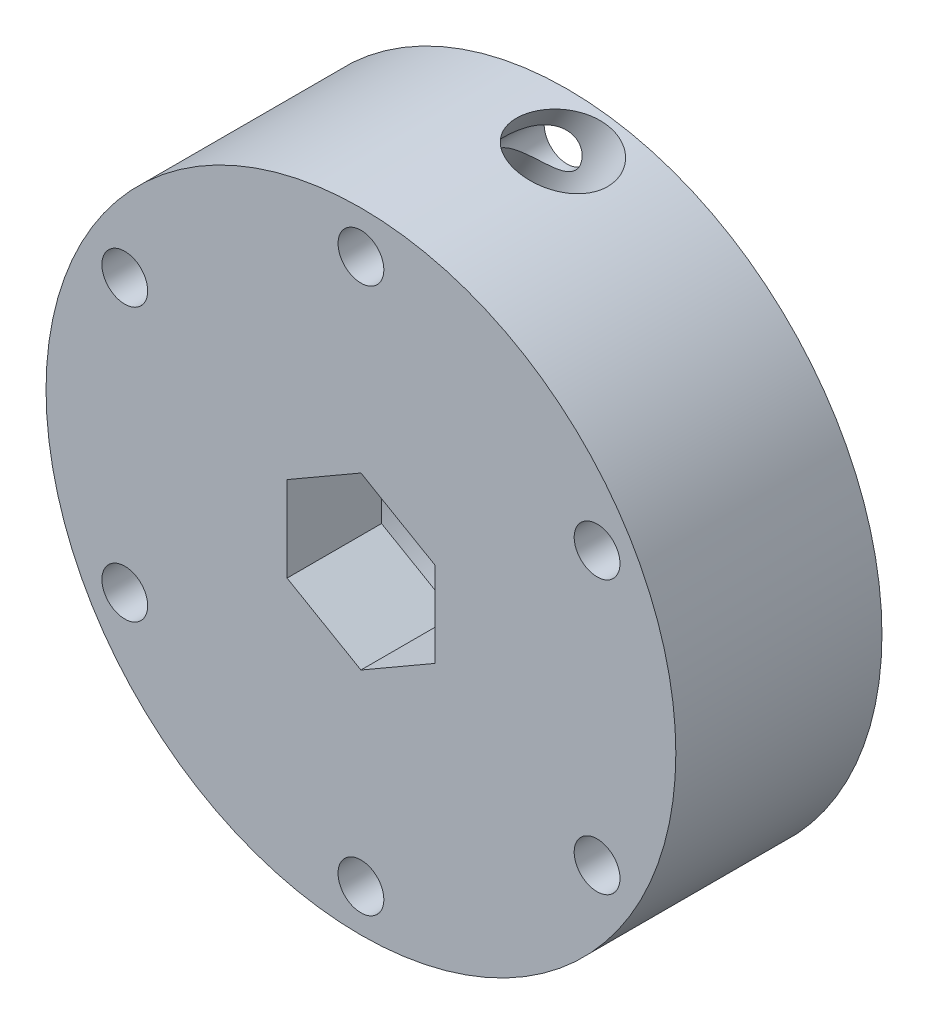
from build123d import *

# Parameters (mm, degrees)
SKETCH1_R           = 27.5
SKETCH1_R_2         = 2
BOSS_EXTRUDE1_DEPTH = 18
CUT_EXTRUDE1_DEPTH  = 19
SKETCH3_R           = 15.675
CUT_EXTRUDE2_DEPTH  = 9.75
SKETCH5_R           = 3.75
CUT_EXTRUDE4_DEPTH  = 32.114098604


with BuildPart() as part:
    # Sketch1 → Boss-Extrude1 (new body)
    with BuildSketch(Plane.XY):
        Circle(SKETCH1_R)
        with Locations((0, 23.8125)):
            Circle(SKETCH1_R_2, mode=Mode.SUBTRACT)
        with Locations((20.622229928, 11.90625)):
            Circle(SKETCH1_R_2, mode=Mode.SUBTRACT)
        with Locations((20.622229928, -11.90625)):
            Circle(SKETCH1_R_2, mode=Mode.SUBTRACT)
        with Locations((0, -23.8125)):
            Circle(SKETCH1_R_2, mode=Mode.SUBTRACT)
        with Locations((-20.622229928, -11.90625)):
            Circle(SKETCH1_R_2, mode=Mode.SUBTRACT)
        with Locations((-20.622229928, 11.90625)):
            Circle(SKETCH1_R_2, mode=Mode.SUBTRACT)
    extrude(amount=BOSS_EXTRUDE1_DEPTH)

    # Sketch2 → Cut-Extrude1 (cut, through all)
    with BuildSketch(Plane(origin=(0, 0, 0), x_dir=(-1, 0, 0), z_dir=(0, 0, -1))):
        Polygon((0, 7.449665993), (-6.4516, 3.724832997), (-6.4516, -3.724832997), (0, -7.449665993), (6.4516, -3.724832997), (6.4516, 3.724832997), align=None)
    extrude(amount=-CUT_EXTRUDE1_DEPTH, mode=Mode.SUBTRACT)

    # Sketch3 → Cut-Extrude2 (cut)
    with BuildSketch(Plane(origin=(0, 0, 0), x_dir=(-1, 0, 0), z_dir=(0, 0, -1))):
        Circle(SKETCH3_R)
    extrude(amount=-CUT_EXTRUDE2_DEPTH, mode=Mode.SUBTRACT)

    # Sketch5 → Cut-Extrude4 (cut, through all)
    with BuildSketch(Plane(origin=(0.225707929, 7.31935346, 0), x_dir=(0.866025404, -0.5, 0), z_dir=(-0.5, -0.866025404, 0))):
        with Locations((-6.535792071, 4.426010426)):
            Circle(SKETCH5_R)
    extrude(amount=-CUT_EXTRUDE4_DEPTH, mode=Mode.SUBTRACT)


solid = part.part
